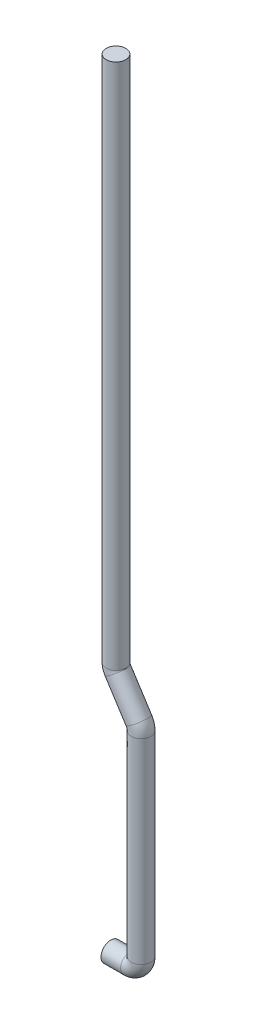
from build123d import *

# Parameters (mm, degrees)
SKETCH17_R = 4


with BuildPart() as part:
    # Sweep22: sweep along a path in Sketch3
    with BuildLine(Plane.XY) as sweep22_path:
        Line((0, 0), (8, 0))
        ThreePointArc((8, 0), (11.076281797, 1.274237642), (12.350519439, 4.350519439))
        Line((12.350519439, 4.350519439), (12.350519439, 84.031538443))
        ThreePointArc((12.350519439, 84.031538443), (12.105003941, 85.738751653), (11.388356434, 87.307595544))
        Line((11.388356434, 87.307595544), (2.803075983, 100.662825163))
        ThreePointArc((2.803075983, 100.662825163), (2.288452214, 101.789410198), (2.112147811, 103.015358086))
        Line((2.112147811, 103.015358086), (2.112147811, 317.721722854))
    # Sketch17 → Sweep22 (sweep)
    with BuildSketch(Plane(origin=(0, 0, 0), x_dir=(0, 0, -1), z_dir=(1, 0, 0))):
        Circle(SKETCH17_R)
    sweep(path=sweep22_path.line)


solid = part.part
